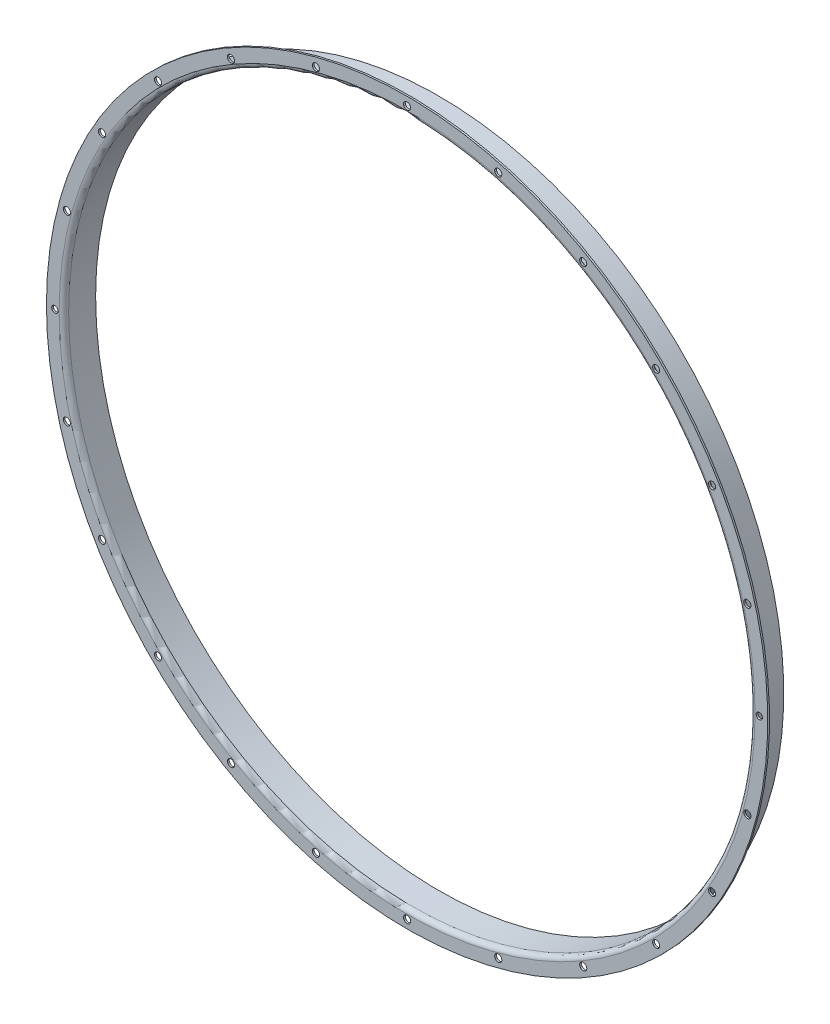
from build123d import *

# Parameters (mm, degrees)
M4_CLEARANCE_HOLE1_D = 4.5
CIRPATTERN1_COUNT    = 24
SKETCH6_R            = 2.25
SKETCH6_R_2          = 2
BOSS_EXTRUDE1_DEPTH  = 1.1


with BuildPart() as part:
    # Sweep1: sweep along a path in Sketch1
    with BuildLine(Plane.XY) as sweep1_path:
        CenterArc((0, 0), 216.325, 0, 360)
    # Sketch2 → Sweep1 (sweep)
    with BuildSketch(Plane(origin=(0, 0, 0), x_dir=(0, 0, -1), z_dir=(1, 0, 0))):
        with BuildLine():
            Line((0, 227.325), (0, 219.325))
            ThreePointArc((0, 219.325), (0.878679656, 217.203679656), (3, 216.325))
            Line((3, 216.325), (20, 216.325))
            Line((20, 216.325), (20, 217.425))
            Line((20, 217.425), (3.1, 217.425))
            ThreePointArc((3.1, 217.425), (1.685786438, 218.010786438), (1.1, 219.425))
            Line((1.1, 219.425), (1.1, 227.325))
            Line((1.1, 227.325), (0, 227.325))
        make_face()
    sweep(path=sweep1_path.line)

    # M4 Clearance Hole1 (through all)
    with Locations(Plane.XY):
        with Locations((0, 222)):
            m4_clearance_hole1 = Hole(M4_CLEARANCE_HOLE1_D / 2)

    # CirPattern1: M4 Clearance Hole1 ×24 about axis
    cirpattern1_axis = Axis((0, 0, 0), (0, 0, 1))
    for i in range(1, CIRPATTERN1_COUNT):
        add(m4_clearance_hole1.rotate(cirpattern1_axis, i * 360 / CIRPATTERN1_COUNT), mode=Mode.SUBTRACT)

    # Sketch6 → Boss-Extrude1 (add)
    with BuildSketch(Plane.XY):
        with Locations((-222, 0)):
            Circle(SKETCH6_R)
        with Locations((-222, 0)):
            Circle(SKETCH6_R_2, mode=Mode.SUBTRACT)
        with Locations((222, 0)):
            Circle(SKETCH6_R)
        with Locations((222, 0)):
            Circle(SKETCH6_R_2, mode=Mode.SUBTRACT)
    extrude(amount=-BOSS_EXTRUDE1_DEPTH)


solid = part.part
